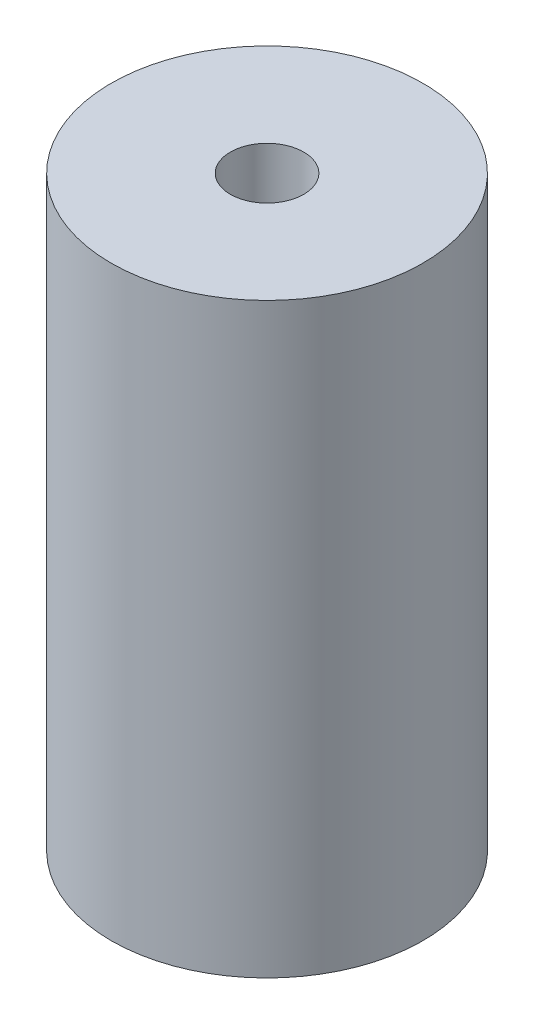
from build123d import *

# Parameters (mm, degrees)
SKETCH1_R                = 26.9875
SKETCH1_R_2              = 6.35
BOSS_EXTRUDE1_DEPTH      = 95.25
BOSS_EXTRUDE1_DEPTH_BACK = 6.35


with BuildPart() as part:
    # Sketch1 → Boss-Extrude1 (new body, two sides)
    with BuildSketch(Plane(origin=(0, 0, 0), x_dir=(1, 0, 0), z_dir=(0, 1, 0))) as boss_extrude1_sk:
        Circle(SKETCH1_R)
        Circle(SKETCH1_R_2, mode=Mode.SUBTRACT)
    extrude(amount=BOSS_EXTRUDE1_DEPTH)
    extrude(boss_extrude1_sk.sketch, amount=-BOSS_EXTRUDE1_DEPTH_BACK)


solid = part.part
